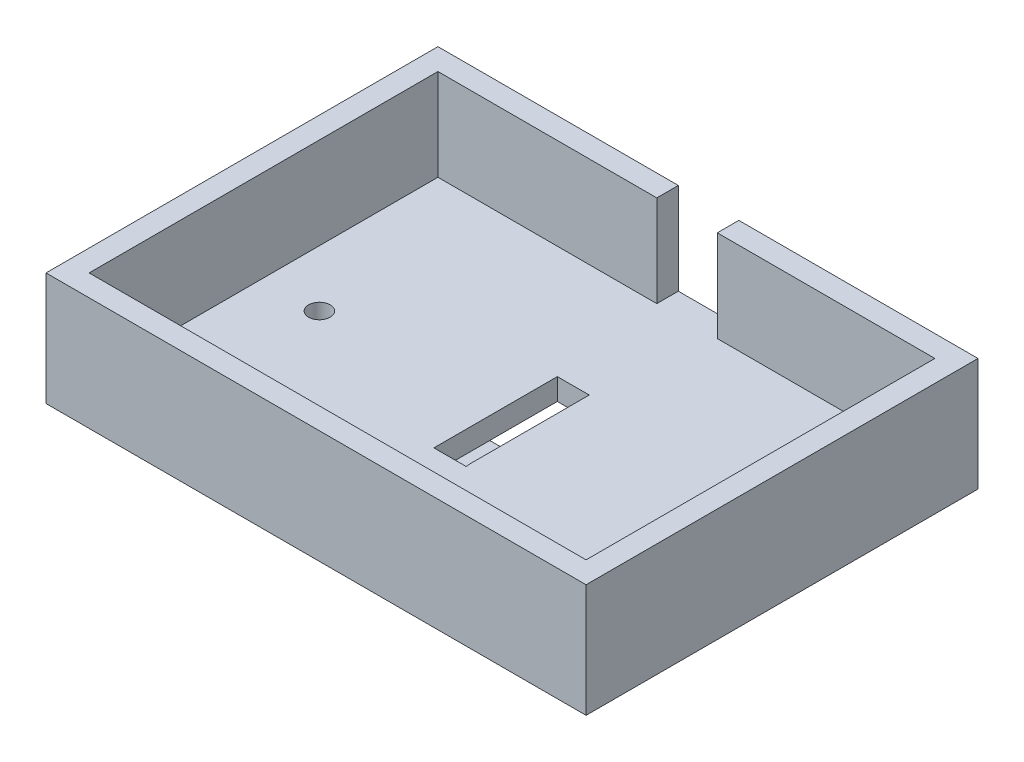
from build123d import *

# Parameters (mm, degrees)
SKETCH1_W           = 100.25
SKETCH1_H           = 72.75
BOSS_EXTRUDE1_DEPTH = 4
SKETCH1_3_W         = 100.25
SKETCH1_3_H         = 72.75
SKETCH1_3_W_2       = 92.25
SKETCH1_3_H_2       = 64.75
BOSS_EXTRUDE2_DEPTH = 21
CUT_EXTRUDE1_DEPTH  = 21
CUT_EXTRUDE3_DEPTH  = 21
SKETCH5_W           = 4
SKETCH5_H           = 4
BOSS_EXTRUDE3_DEPTH = 9.5
SKETCH7_W           = 4
SKETCH7_H           = 4
BOSS_EXTRUDE4_DEPTH = 20
SKETCH8_W           = 11.232726049
SKETCH8_H           = 17
CUT_EXTRUDE4_DEPTH  = 10
SKETCH10_W          = 5.918371549
SKETCH10_H          = 22.91291731
CUT_EXTRUDE5_DEPTH  = 10


with BuildPart() as part:
    # Sketch1 → Boss-Extrude1 (new body)
    with BuildSketch(Plane(origin=(0, 0, 0), x_dir=(1, 0, 0), z_dir=(0, 1, 0))):
        with Locations((4.210861322, -6.421587216)):
            Rectangle(SKETCH1_W, SKETCH1_H)
    extrude(amount=BOSS_EXTRUDE1_DEPTH)

    # Sketch1_3 → Boss-Extrude2 (add)
    with BuildSketch(Plane(origin=(0, 0, 0), x_dir=(1, 0, 0), z_dir=(0, 1, 0))):
        with Locations((4.210861322, -6.421587216)):
            Rectangle(SKETCH1_3_W, SKETCH1_3_H)
        with Locations((4.210861322, -6.421587216)):
            Rectangle(SKETCH1_3_W_2, SKETCH1_3_H_2, mode=Mode.SUBTRACT)
    extrude(amount=BOSS_EXTRUDE2_DEPTH)

    # Sketch2 → Cut-Extrude1 (cut)
    with BuildSketch(Plane.XZ):
        Polygon((1.210861322, 17.921587216), (1.210861322, -4.953073118), (4.812963363, -4.953073118), (7.210861322, 17.921587216), align=None)
    extrude(amount=-CUT_EXTRUDE1_DEPTH, mode=Mode.SUBTRACT)

    # Sketch2_4 → Cut-Extrude3 (cut)
    with BuildSketch(Plane.XZ):
        with BuildLine():
            ThreePointArc((-33.414603129, 6.529341832), (-31.406056992, 4.546601149), (-29.414677441, 6.546582571))
            ThreePointArc((-29.414677441, 6.546582571), (-31.423297891, 8.546563993), (-33.414603129, 6.529341832))
        make_face()
    extrude(amount=-CUT_EXTRUDE3_DEPTH, mode=Mode.SUBTRACT)

    # Sketch5 → Boss-Extrude3 (add)
    with BuildSketch(Plane(origin=(0, 0, 0), x_dir=(-1, 0, 0), z_dir=(0, -1, 0))):
        with Locations((-10.710861322, -23.921587216)):
            Rectangle(SKETCH5_W, SKETCH5_H)
        with Locations((2.289138678, -24.046587216)):
            Rectangle(SKETCH5_W, SKETCH5_H)
    extrude(amount=BOSS_EXTRUDE3_DEPTH)

    # Sketch7 → Boss-Extrude4 (add)
    with BuildSketch(Plane(origin=(0, 0, 22.046587216), x_dir=(-1, 0, 0), z_dir=(0, 0, -1))):
        with Locations((2.289138678, -7.5)):
            Rectangle(SKETCH7_W, SKETCH7_H)
        with Locations((-10.710861322, -7.5)):
            Rectangle(SKETCH7_W, SKETCH7_H)
    extrude(amount=BOSS_EXTRUDE4_DEPTH)

    # Sketch8 → Cut-Extrude4 (cut)
    with BuildSketch(Plane(origin=(0, 0, -29.953412784), x_dir=(-1, 0, 0), z_dir=(0, 0, -1))):
        with Locations((-4.327224347, 12.5)):
            Rectangle(SKETCH8_W, SKETCH8_H)
    extrude(amount=-CUT_EXTRUDE4_DEPTH, mode=Mode.SUBTRACT)

    # Sketch10 → Cut-Extrude5 (cut)
    with BuildSketch(Plane.XZ):
        with Locations((4.170047097, 6.465128561)):
            Rectangle(SKETCH10_W, SKETCH10_H)
    extrude(amount=-CUT_EXTRUDE5_DEPTH, mode=Mode.SUBTRACT)


solid = part.part
